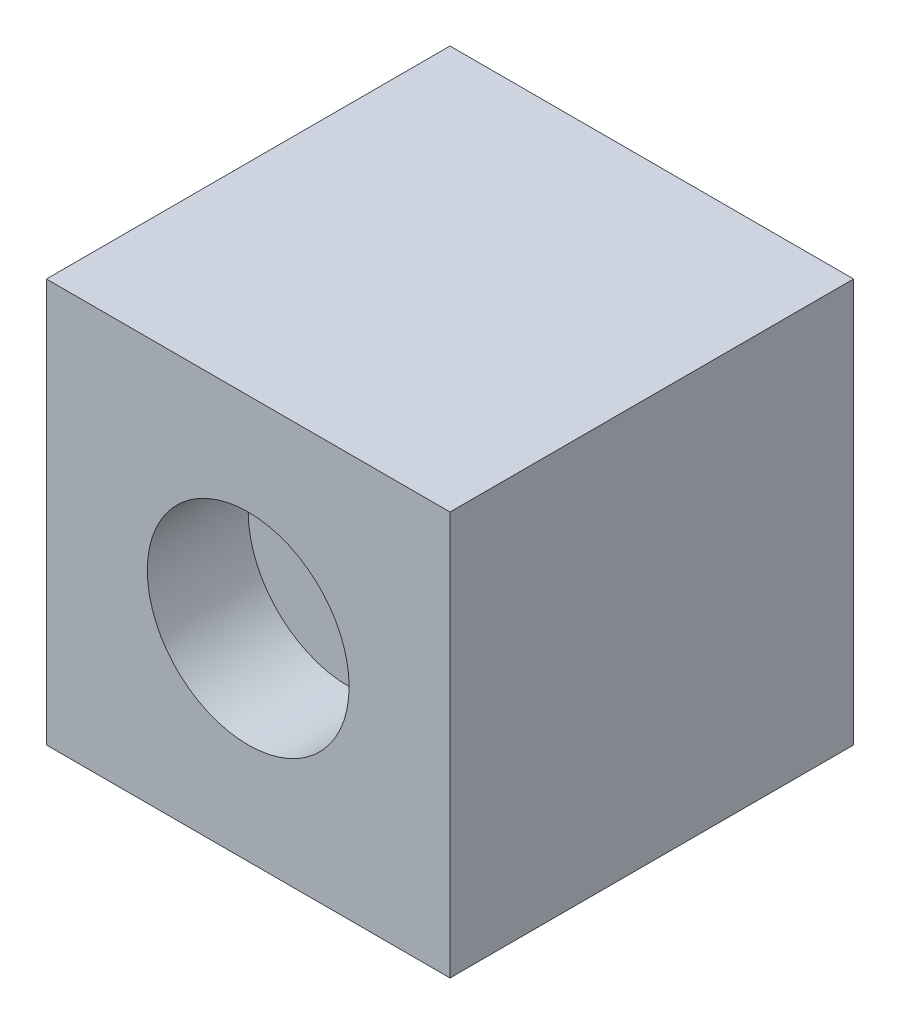
from build123d import *

# Parameters (mm, degrees)
SKETCH2_W           = 50.8
SKETCH2_H           = 50.8
BOSS_EXTRUDE1_DEPTH = 50.8
SKETCH3_R           = 12.7
CUT_EXTRUDE1_DEPTH  = 12.7


with BuildPart() as part:
    # Sketch2 → Boss-Extrude1 (new body)
    with BuildSketch(Plane.XY):
        Rectangle(SKETCH2_W, SKETCH2_H)
    extrude(amount=BOSS_EXTRUDE1_DEPTH)

    # Sketch3 → Cut-Extrude1 (cut)
    with BuildSketch(Plane.XY.offset(50.8)):
        Circle(SKETCH3_R)
    extrude(amount=-CUT_EXTRUDE1_DEPTH, mode=Mode.SUBTRACT)


solid = part.part
